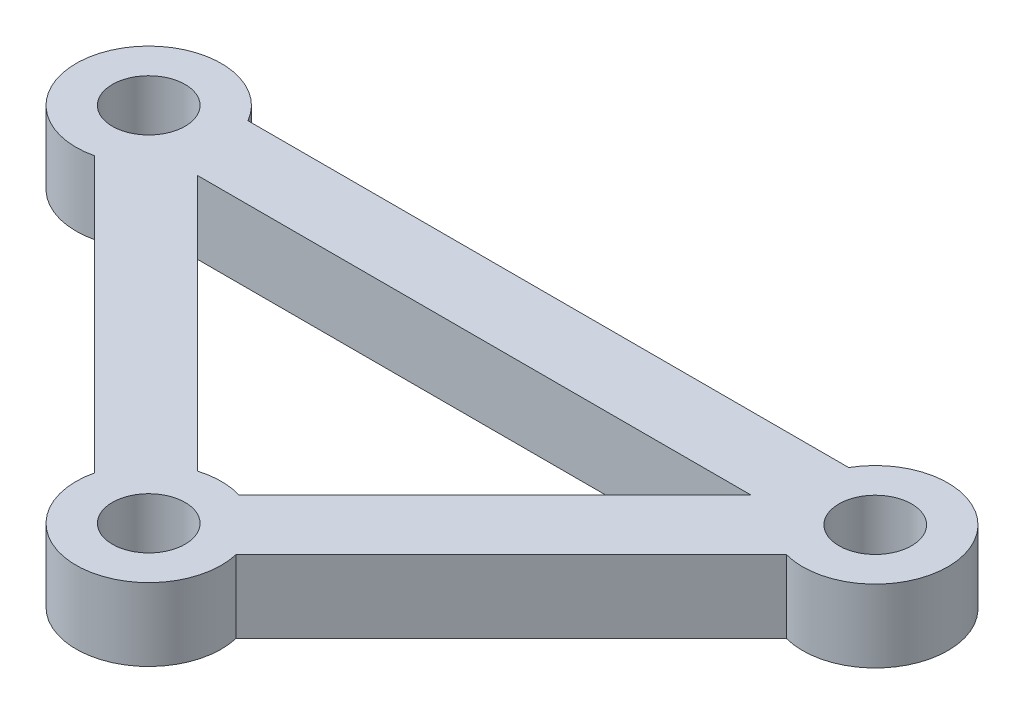
from build123d import *

# Parameters (mm, degrees)
BOSS_EXTRUDE1_DEPTH   = 5
F_5_0MM_DOWEL_HOLE1_D = 5


with BuildPart() as part:
    # Sketch2 → Boss-Extrude1 (new body)
    with BuildSketch(Plane(origin=(0, 0, 0), x_dir=(1, 0, 0), z_dir=(0, 1, 0))):
        with BuildLine():
            Line((-32.269872981, 20.929032067), (9.069872981, 20.929032067))
            ThreePointArc((9.069872981, 20.929032067), (18.019397663, 20.342449229), (12.105904774, 13.599402936))
            Line((12.105904774, 13.599402936), (-6.82412184, -5.330623679))
            ThreePointArc((-6.82412184, -5.330623679), (-11.690092491, -11.4805496), (-16.556063141, -5.330623679))
            Line((-16.556063141, -5.330623679), (-35.449810526, 13.563123706))
            ThreePointArc((-35.449810526, 13.563123706), (-41.190492208, 20.410794235), (-32.269872981, 20.929032067))
        make_face()
        with BuildLine():
            Line((-30.744651075, 15.929032067), (7.364466094, 15.929032067))
            Line((7.364466094, 15.929032067), (-10.255377332, -1.690811359))
            ThreePointArc((-10.255377332, -1.690811359), (-11.690092491, -1.4805496), (-13.124807649, -1.690811359))
            Line((-13.124807649, -1.690811359), (-30.744651075, 15.929032067))
        make_face(mode=Mode.SUBTRACT)
    extrude(amount=BOSS_EXTRUDE1_DEPTH)

    # Ø5.0mm Dowel Hole1 (through all)
    with Locations(Plane(origin=(0, 5, 0), x_dir=(1, 0, 0), z_dir=(0, 1, 0))):
        with Locations((13.4, 18.429032067), (-36.6, 18.429032067), (-11.690092491, -6.4805496)):
            Hole(F_5_0MM_DOWEL_HOLE1_D / 2)


solid = part.part
